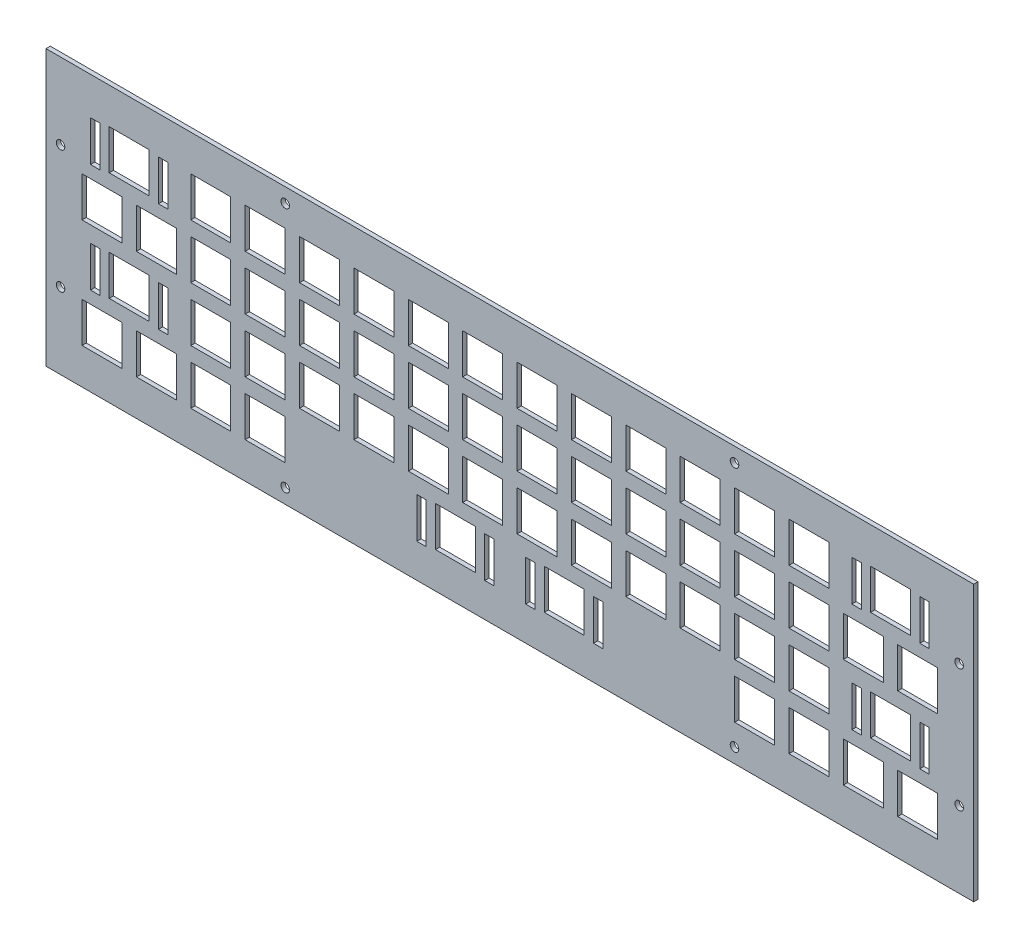
from build123d import *

# Parameters (mm, degrees)
MODEL_W             = 304.8012934
MODEL_H             = 76.2008736
MODEL_W_2           = 13.9995
MODEL_H_2           = 13.9995
MODEL_W_3           = 13.9994
MODEL_W_4           = 13.9992
MODEL_W_5           = 3.302
MODEL_H_3           = 14.2007
MODEL_W_6           = 13.999
MODEL_W_7           = 3.3
MODEL_W_8           = 3.3004
MODEL_H_4           = 14.2005
MODEL_W_9           = 14.0008
MODEL_W_10          = 3.2992
MODEL_W_11          = 13.9991
MODEL_W_12          = 14.001
MODEL_H_5           = 13.9996
BOSS_EXTRUDE2_DEPTH = 1.5
SKETCH3_W           = 324.9887066
SKETCH3_H           = 96.3745066
SKETCH3_W_2         = 304.8012934
SKETCH3_H_2         = 76.2008736
BOSS_EXTRUDE4_DEPTH = 1.5
SKETCH4_R           = 1.5
CUT_EXTRUDE2_DEPTH  = 2.54


with BuildPart() as part:
    # Model → Boss-Extrude2 (new body)
    with BuildSketch(Plane.XY):
        with Locations((162.4943533, 48.1803632)):
            Rectangle(MODEL_W, MODEL_H)
        with Locations((19.61845, 19.60605)):
            Rectangle(MODEL_W_2, MODEL_H_2, mode=Mode.SUBTRACT)
        with Locations((38.6684, 19.60605)):
            Rectangle(MODEL_W_3, MODEL_H_2, mode=Mode.SUBTRACT)
        with Locations((57.7185, 19.60605)):
            Rectangle(MODEL_W_4, MODEL_H_2, mode=Mode.SUBTRACT)
        with Locations((76.7685, 19.60605)):
            Rectangle(MODEL_W_4, MODEL_H_2, mode=Mode.SUBTRACT)
        with Locations((131.543, 18.95565)):
            Rectangle(MODEL_W_5, MODEL_H_3, mode=Mode.SUBTRACT)
        with Locations((143.4435, 19.60605)):
            Rectangle(MODEL_W_6, MODEL_H_2, mode=Mode.SUBTRACT)
        with Locations((155.344, 18.95565)):
            Rectangle(MODEL_W_7, MODEL_H_3, mode=Mode.SUBTRACT)
        with Locations((17.2427, 38.00555)):
            Rectangle(MODEL_W_8, MODEL_H_4, mode=Mode.SUBTRACT)
        with Locations((29.1427, 38.65605)):
            Rectangle(MODEL_W_9, MODEL_H_2, mode=Mode.SUBTRACT)
        with Locations((41.0436, 38.00555)):
            Rectangle(MODEL_W_10, MODEL_H_4, mode=Mode.SUBTRACT)
        with Locations((57.7185, 38.65605)):
            Rectangle(MODEL_W_4, MODEL_H_2, mode=Mode.SUBTRACT)
        with Locations((76.7685, 38.65605)):
            Rectangle(MODEL_W_4, MODEL_H_2, mode=Mode.SUBTRACT)
        with Locations((95.81845, 38.65605)):
            Rectangle(MODEL_W_11, MODEL_H_2, mode=Mode.SUBTRACT)
        with Locations((114.8675, 38.65605)):
            Rectangle(MODEL_W_12, MODEL_H_2, mode=Mode.SUBTRACT)
        with Locations((133.9185, 38.65605)):
            Rectangle(MODEL_W_6, MODEL_H_2, mode=Mode.SUBTRACT)
        with Locations((152.9685, 38.65605)):
            Rectangle(MODEL_W_6, MODEL_H_2, mode=Mode.SUBTRACT)
        with Locations((169.643, 18.95565)):
            Rectangle(MODEL_W_5, MODEL_H_3, mode=Mode.SUBTRACT)
        with Locations((181.5435, 19.60605)):
            Rectangle(MODEL_W_6, MODEL_H_2, mode=Mode.SUBTRACT)
        with Locations((193.444, 18.95565)):
            Rectangle(MODEL_W_7, MODEL_H_3, mode=Mode.SUBTRACT)
        with Locations((248.2185, 19.60605)):
            Rectangle(MODEL_W_6, MODEL_H_2, mode=Mode.SUBTRACT)
        with Locations((267.2685, 19.60605)):
            Rectangle(MODEL_W_6, MODEL_H_2, mode=Mode.SUBTRACT)
        with Locations((286.3185, 19.60605)):
            Rectangle(MODEL_W_6, MODEL_H_2, mode=Mode.SUBTRACT)
        with Locations((305.3685, 19.60605)):
            Rectangle(MODEL_W_6, MODEL_H_2, mode=Mode.SUBTRACT)
        with Locations((172.0185, 38.65605)):
            Rectangle(MODEL_W_6, MODEL_H_2, mode=Mode.SUBTRACT)
        with Locations((191.0685, 38.65605)):
            Rectangle(MODEL_W_6, MODEL_H_2, mode=Mode.SUBTRACT)
        with Locations((210.1185, 38.65605)):
            Rectangle(MODEL_W_6, MODEL_H_2, mode=Mode.SUBTRACT)
        with Locations((229.1685, 38.65605)):
            Rectangle(MODEL_W_6, MODEL_H_2, mode=Mode.SUBTRACT)
        with Locations((248.2185, 38.65605)):
            Rectangle(MODEL_W_6, MODEL_H_2, mode=Mode.SUBTRACT)
        with Locations((267.2685, 38.65605)):
            Rectangle(MODEL_W_6, MODEL_H_2, mode=Mode.SUBTRACT)
        with Locations((283.944, 38.00555)):
            Rectangle(MODEL_W_7, MODEL_H_4, mode=Mode.SUBTRACT)
        with Locations((295.8435, 38.65605)):
            Rectangle(MODEL_W_6, MODEL_H_2, mode=Mode.SUBTRACT)
        with Locations((307.744, 38.00555)):
            Rectangle(MODEL_W_7, MODEL_H_4, mode=Mode.SUBTRACT)
        with Locations((19.61845, 57.706)):
            Rectangle(MODEL_W_2, MODEL_H_5, mode=Mode.SUBTRACT)
        with Locations((38.6684, 57.706)):
            Rectangle(MODEL_W_3, MODEL_H_5, mode=Mode.SUBTRACT)
        with Locations((57.7185, 57.706)):
            Rectangle(MODEL_W_4, MODEL_H_5, mode=Mode.SUBTRACT)
        with Locations((76.7685, 57.706)):
            Rectangle(MODEL_W_4, MODEL_H_5, mode=Mode.SUBTRACT)
        with Locations((95.81845, 57.706)):
            Rectangle(MODEL_W_11, MODEL_H_5, mode=Mode.SUBTRACT)
        with Locations((114.8675, 57.706)):
            Rectangle(MODEL_W_12, MODEL_H_5, mode=Mode.SUBTRACT)
        with Locations((133.9185, 57.706)):
            Rectangle(MODEL_W_6, MODEL_H_5, mode=Mode.SUBTRACT)
        with Locations((152.9685, 57.706)):
            Rectangle(MODEL_W_6, MODEL_H_5, mode=Mode.SUBTRACT)
        with Locations((17.2427, 76.10545)):
            Rectangle(MODEL_W_8, MODEL_H_3, mode=Mode.SUBTRACT)
        with Locations((29.1427, 76.756)):
            Rectangle(MODEL_W_9, MODEL_H_5, mode=Mode.SUBTRACT)
        with Locations((41.0436, 76.10545)):
            Rectangle(MODEL_W_10, MODEL_H_3, mode=Mode.SUBTRACT)
        with Locations((57.7185, 76.756)):
            Rectangle(MODEL_W_4, MODEL_H_5, mode=Mode.SUBTRACT)
        with Locations((76.7685, 76.756)):
            Rectangle(MODEL_W_4, MODEL_H_5, mode=Mode.SUBTRACT)
        with Locations((95.81845, 76.756)):
            Rectangle(MODEL_W_11, MODEL_H_5, mode=Mode.SUBTRACT)
        with Locations((114.8675, 76.756)):
            Rectangle(MODEL_W_12, MODEL_H_5, mode=Mode.SUBTRACT)
        with Locations((133.9185, 76.756)):
            Rectangle(MODEL_W_6, MODEL_H_5, mode=Mode.SUBTRACT)
        with Locations((152.9685, 76.756)):
            Rectangle(MODEL_W_6, MODEL_H_5, mode=Mode.SUBTRACT)
        with Locations((172.0185, 57.706)):
            Rectangle(MODEL_W_6, MODEL_H_5, mode=Mode.SUBTRACT)
        with Locations((191.0685, 57.706)):
            Rectangle(MODEL_W_6, MODEL_H_5, mode=Mode.SUBTRACT)
        with Locations((210.1185, 57.706)):
            Rectangle(MODEL_W_6, MODEL_H_5, mode=Mode.SUBTRACT)
        with Locations((229.1685, 57.706)):
            Rectangle(MODEL_W_6, MODEL_H_5, mode=Mode.SUBTRACT)
        with Locations((248.2185, 57.706)):
            Rectangle(MODEL_W_6, MODEL_H_5, mode=Mode.SUBTRACT)
        with Locations((267.2685, 57.706)):
            Rectangle(MODEL_W_6, MODEL_H_5, mode=Mode.SUBTRACT)
        with Locations((286.3185, 57.706)):
            Rectangle(MODEL_W_6, MODEL_H_5, mode=Mode.SUBTRACT)
        with Locations((305.3685, 57.706)):
            Rectangle(MODEL_W_6, MODEL_H_5, mode=Mode.SUBTRACT)
        with Locations((172.0185, 76.756)):
            Rectangle(MODEL_W_6, MODEL_H_5, mode=Mode.SUBTRACT)
        with Locations((191.0685, 76.756)):
            Rectangle(MODEL_W_6, MODEL_H_5, mode=Mode.SUBTRACT)
        with Locations((210.1185, 76.756)):
            Rectangle(MODEL_W_6, MODEL_H_5, mode=Mode.SUBTRACT)
        with Locations((229.1685, 76.756)):
            Rectangle(MODEL_W_6, MODEL_H_5, mode=Mode.SUBTRACT)
        with Locations((248.2185, 76.756)):
            Rectangle(MODEL_W_6, MODEL_H_5, mode=Mode.SUBTRACT)
        with Locations((267.2685, 76.756)):
            Rectangle(MODEL_W_6, MODEL_H_5, mode=Mode.SUBTRACT)
        with Locations((283.944, 76.10545)):
            Rectangle(MODEL_W_7, MODEL_H_3, mode=Mode.SUBTRACT)
        with Locations((295.8435, 76.756)):
            Rectangle(MODEL_W_6, MODEL_H_5, mode=Mode.SUBTRACT)
        with Locations((307.744, 76.10545)):
            Rectangle(MODEL_W_7, MODEL_H_3, mode=Mode.SUBTRACT)
    extrude(amount=BOSS_EXTRUDE2_DEPTH)

    # Sketch3 → Boss-Extrude4 (add)
    with BuildSketch(Plane.XY.offset(1.5)):
        with Locations((162.4943533, 48.1872533)):
            Rectangle(SKETCH3_W, SKETCH3_H)
        with Locations((162.4943533, 48.1803632)):
            Rectangle(SKETCH3_W_2, SKETCH3_H_2, mode=Mode.SUBTRACT)
    extrude(amount=-BOSS_EXTRUDE4_DEPTH)

    # Sketch4 → Cut-Extrude2 (cut)
    with BuildSketch(Plane.XY):
        with Locations((5.0937066, 69.7305816)):
            Circle(SKETCH4_R)
        with Locations((5.0937066, 26.6301448)):
            Circle(SKETCH4_R)
        with Locations((83.79402995, 5.0799264)):
            Circle(SKETCH4_R)
        with Locations((241.19467665, 5.0799264)):
            Circle(SKETCH4_R)
        with Locations((319.895, 26.6301448)):
            Circle(SKETCH4_R)
        with Locations((319.895, 69.7305816)):
            Circle(SKETCH4_R)
        with Locations((241.19467665, 91.2808)):
            Circle(SKETCH4_R)
        with Locations((83.79402995, 91.2808)):
            Circle(SKETCH4_R)
    extrude(amount=CUT_EXTRUDE2_DEPTH, mode=Mode.SUBTRACT)


solid = part.part
